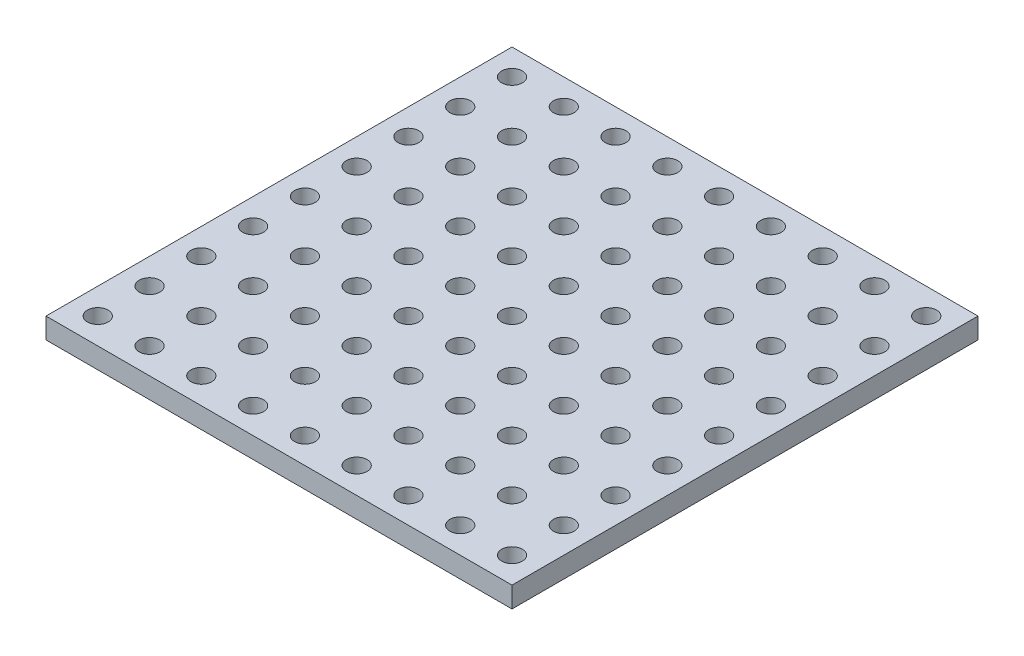
from build123d import *

# Parameters (mm, degrees)
ESBO_O1_W                = 450
ESBO_O1_H                = 450
RESSALTO_EXTRUS_O1_DEPTH = 20
ESBO_O2_R                = 10
CORTE_EXTRUS_O1_DEPTH    = 21


with BuildPart() as part:
    # Esboço1 → Ressalto-extrusão1 (new body)
    with BuildSketch(Plane(origin=(0, 0, 0), x_dir=(1, 0, 0), z_dir=(0, 1, 0))):
        Rectangle(ESBO_O1_W, ESBO_O1_H)
    extrude(amount=RESSALTO_EXTRUS_O1_DEPTH)

    # Esboço2 → Corte-extrusão1 (cut, through all)
    with BuildSketch(Plane(origin=(0, 20, 0), x_dir=(1, 0, 0), z_dir=(0, 1, 0))):
        with Locations((-200, 200)):
            Circle(ESBO_O2_R)
        with Locations((-150, 200)):
            Circle(ESBO_O2_R)
        with Locations((-100, 200)):
            Circle(ESBO_O2_R)
        with Locations((-50, 200)):
            Circle(ESBO_O2_R)
        with Locations((0, 200)):
            Circle(ESBO_O2_R)
        with Locations((50, 200)):
            Circle(ESBO_O2_R)
        with Locations((100, 200)):
            Circle(ESBO_O2_R)
        with Locations((150, 200)):
            Circle(ESBO_O2_R)
        with Locations((200, 200)):
            Circle(ESBO_O2_R)
        with Locations((250, 200)):
            Circle(ESBO_O2_R)
        with Locations((-150, 150)):
            Circle(ESBO_O2_R)
        with Locations((-100, 150)):
            Circle(ESBO_O2_R)
        with Locations((-50, 150)):
            Circle(ESBO_O2_R)
        with Locations((0, 150)):
            Circle(ESBO_O2_R)
        with Locations((50, 150)):
            Circle(ESBO_O2_R)
        with Locations((100, 150)):
            Circle(ESBO_O2_R)
        with Locations((150, 150)):
            Circle(ESBO_O2_R)
        with Locations((200, 150)):
            Circle(ESBO_O2_R)
        with Locations((250, 150)):
            Circle(ESBO_O2_R)
        with Locations((-150, 100)):
            Circle(ESBO_O2_R)
        with Locations((-100, 100)):
            Circle(ESBO_O2_R)
        with Locations((-50, 100)):
            Circle(ESBO_O2_R)
        with Locations((0, 100)):
            Circle(ESBO_O2_R)
        with Locations((50, 100)):
            Circle(ESBO_O2_R)
        with Locations((100, 100)):
            Circle(ESBO_O2_R)
        with Locations((150, 100)):
            Circle(ESBO_O2_R)
        with Locations((200, 100)):
            Circle(ESBO_O2_R)
        with Locations((250, 100)):
            Circle(ESBO_O2_R)
        with Locations((-150, 50)):
            Circle(ESBO_O2_R)
        with Locations((-100, 50)):
            Circle(ESBO_O2_R)
        with Locations((-50, 50)):
            Circle(ESBO_O2_R)
        with Locations((0, 50)):
            Circle(ESBO_O2_R)
        with Locations((50, 50)):
            Circle(ESBO_O2_R)
        with Locations((100, 50)):
            Circle(ESBO_O2_R)
        with Locations((150, 50)):
            Circle(ESBO_O2_R)
        with Locations((200, 50)):
            Circle(ESBO_O2_R)
        with Locations((250, 50)):
            Circle(ESBO_O2_R)
        with Locations((-150, 0)):
            Circle(ESBO_O2_R)
        with Locations((-100, 0)):
            Circle(ESBO_O2_R)
        with Locations((-50, 0)):
            Circle(ESBO_O2_R)
        Circle(ESBO_O2_R)
        with Locations((50, 0)):
            Circle(ESBO_O2_R)
        with Locations((100, 0)):
            Circle(ESBO_O2_R)
        with Locations((150, 0)):
            Circle(ESBO_O2_R)
        with Locations((200, 0)):
            Circle(ESBO_O2_R)
        with Locations((250, 0)):
            Circle(ESBO_O2_R)
        with Locations((-150, -50)):
            Circle(ESBO_O2_R)
        with Locations((-100, -50)):
            Circle(ESBO_O2_R)
        with Locations((-50, -50)):
            Circle(ESBO_O2_R)
        with Locations((0, -50)):
            Circle(ESBO_O2_R)
        with Locations((50, -50)):
            Circle(ESBO_O2_R)
        with Locations((100, -50)):
            Circle(ESBO_O2_R)
        with Locations((150, -50)):
            Circle(ESBO_O2_R)
        with Locations((200, -50)):
            Circle(ESBO_O2_R)
        with Locations((250, -50)):
            Circle(ESBO_O2_R)
        with Locations((-150, -100)):
            Circle(ESBO_O2_R)
        with Locations((-100, -100)):
            Circle(ESBO_O2_R)
        with Locations((-50, -100)):
            Circle(ESBO_O2_R)
        with Locations((0, -100)):
            Circle(ESBO_O2_R)
        with Locations((50, -100)):
            Circle(ESBO_O2_R)
        with Locations((100, -100)):
            Circle(ESBO_O2_R)
        with Locations((150, -100)):
            Circle(ESBO_O2_R)
        with Locations((200, -100)):
            Circle(ESBO_O2_R)
        with Locations((250, -100)):
            Circle(ESBO_O2_R)
        with Locations((-150, -150)):
            Circle(ESBO_O2_R)
        with Locations((-100, -150)):
            Circle(ESBO_O2_R)
        with Locations((-50, -150)):
            Circle(ESBO_O2_R)
        with Locations((0, -150)):
            Circle(ESBO_O2_R)
        with Locations((50, -150)):
            Circle(ESBO_O2_R)
        with Locations((100, -150)):
            Circle(ESBO_O2_R)
        with Locations((150, -150)):
            Circle(ESBO_O2_R)
        with Locations((200, -150)):
            Circle(ESBO_O2_R)
        with Locations((250, -150)):
            Circle(ESBO_O2_R)
        with Locations((-150, -200)):
            Circle(ESBO_O2_R)
        with Locations((-100, -200)):
            Circle(ESBO_O2_R)
        with Locations((-50, -200)):
            Circle(ESBO_O2_R)
        with Locations((0, -200)):
            Circle(ESBO_O2_R)
        with Locations((50, -200)):
            Circle(ESBO_O2_R)
        with Locations((100, -200)):
            Circle(ESBO_O2_R)
        with Locations((150, -200)):
            Circle(ESBO_O2_R)
        with Locations((200, -200)):
            Circle(ESBO_O2_R)
        with Locations((250, -200)):
            Circle(ESBO_O2_R)
        with Locations((-150, -250)):
            Circle(ESBO_O2_R)
        with Locations((-100, -250)):
            Circle(ESBO_O2_R)
        with Locations((-50, -250)):
            Circle(ESBO_O2_R)
        with Locations((0, -250)):
            Circle(ESBO_O2_R)
        with Locations((50, -250)):
            Circle(ESBO_O2_R)
        with Locations((100, -250)):
            Circle(ESBO_O2_R)
        with Locations((150, -250)):
            Circle(ESBO_O2_R)
        with Locations((200, -250)):
            Circle(ESBO_O2_R)
        with Locations((250, -250)):
            Circle(ESBO_O2_R)
        with Locations((-200, 150)):
            Circle(ESBO_O2_R)
        with Locations((-200, 100)):
            Circle(ESBO_O2_R)
        with Locations((-200, 50)):
            Circle(ESBO_O2_R)
        with Locations((-200, 0)):
            Circle(ESBO_O2_R)
        with Locations((-200, -50)):
            Circle(ESBO_O2_R)
        with Locations((-200, -100)):
            Circle(ESBO_O2_R)
        with Locations((-200, -150)):
            Circle(ESBO_O2_R)
        with Locations((-200, -200)):
            Circle(ESBO_O2_R)
        with Locations((-200, -250)):
            Circle(ESBO_O2_R)
    extrude(amount=-CORTE_EXTRUS_O1_DEPTH, mode=Mode.SUBTRACT)


solid = part.part
